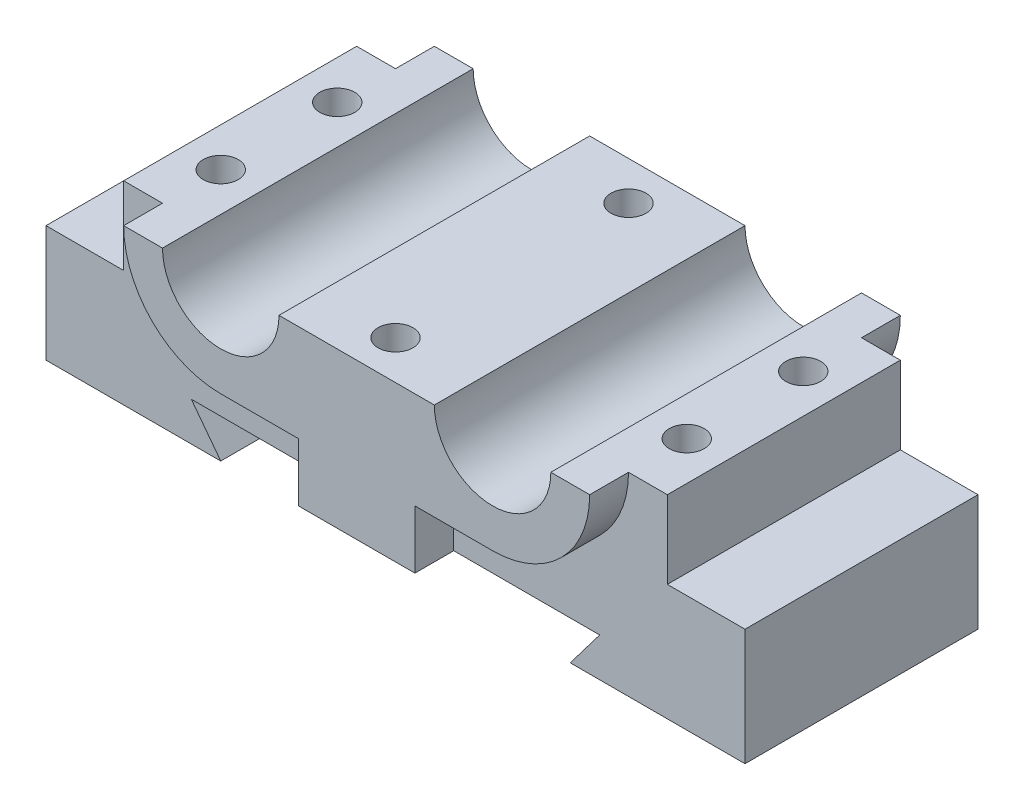
from build123d import *

# Parameters (mm, degrees)
SKETCH1_W                = 90
SKETCH1_H                = 30
BOSS_EXTRUDE1_DEPTH      = 7.5
SKETCH2_W                = 70
SKETCH2_H                = 30
BOSS_EXTRUDE2_DEPTH      = 10
CUT_EXTRUDE1_DEPTH       = 31
BOSS_EXTRUDE3_DEPTH      = 5
BOSS_EXTRUDE3_DEPTH_BACK = 35
CUT_EXTRUDE2_DEPTH       = 30
SKETCH7_R                = 2.25
CUT_EXTRUDE3_DEPTH       = 15


with BuildPart() as part:
    # Sketch1 → Boss-Extrude1 (new body, symmetric)
    with BuildSketch(Plane(origin=(0, 0, 0), x_dir=(1, 0, 0), z_dir=(0, 1, 0))):
        Rectangle(SKETCH1_W, SKETCH1_H)
    extrude(amount=BOSS_EXTRUDE1_DEPTH, both=True)

    # Sketch2 → Boss-Extrude2 (add)
    with BuildSketch(Plane(origin=(0, 7.5, 0), x_dir=(1, 0, 0), z_dir=(0, 1, 0))):
        Rectangle(SKETCH2_W, SKETCH2_H)
    extrude(amount=BOSS_EXTRUDE2_DEPTH)

    # Sketch3 → Cut-Extrude1 (cut, through all)
    with BuildSketch(Plane.XY.offset(15)):
        Polygon((-26.286782916, -2.5), (26.286782916, -2.5), (22.5, -7.5), (-22.5, -7.5), align=None)
    extrude(amount=-CUT_EXTRUDE1_DEPTH, mode=Mode.SUBTRACT)

    # Sketch4 → Boss-Extrude3 (add, two sides)
    with BuildSketch(Plane.XY.offset(15)) as boss_extrude3_sk:
        with BuildLine():
            Line((-7.5, 5), (-7.5, -2.5))
            Line((-7.5, -2.5), (7.5, -2.5))
            Line((7.5, -2.5), (7.5, 5))
            Line((7.5, 5), (17.5, 5))
            ThreePointArc((17.5, 5), (26.338834765, 8.661165235), (30, 17.5))
            Line((30, 17.5), (25, 17.5))
            ThreePointArc((25, 17.5), (17.5, 10), (10, 17.5))
            Line((10, 17.5), (-10, 17.5))
            ThreePointArc((-10, 17.5), (-17.5, 10), (-25, 17.5))
            Line((-25, 17.5), (-30, 17.5))
            ThreePointArc((-30, 17.5), (-26.338834765, 8.661165235), (-17.5, 5))
            Line((-17.5, 5), (-7.5, 5))
        make_face()
    extrude(amount=BOSS_EXTRUDE3_DEPTH)
    extrude(boss_extrude3_sk.sketch, amount=-BOSS_EXTRUDE3_DEPTH_BACK)

    # Sketch6 → Cut-Extrude2 (cut)
    with BuildSketch(Plane.XY.offset(15)):
        with BuildLine():
            Line((-25, 17.5), (-10, 17.5))
            ThreePointArc((-10, 17.5), (-17.5, 10), (-25, 17.5))
        make_face()
        with BuildLine():
            Line((10, 17.5), (25, 17.5))
            ThreePointArc((25, 17.5), (17.5, 10), (10, 17.5))
        make_face()
    extrude(amount=-CUT_EXTRUDE2_DEPTH, mode=Mode.SUBTRACT)

    # Sketch7 → Cut-Extrude3 (cut)
    with BuildSketch(Plane(origin=(0, 17.5, 0), x_dir=(1, 0, 0), z_dir=(0, 1, 0))):
        with Locations((0, 15)):
            Circle(SKETCH7_R)
        with Locations((0, -15)):
            Circle(SKETCH7_R)
        with Locations((-30, 7.5)):
            Circle(SKETCH7_R)
        with Locations((-30, -7.5)):
            Circle(SKETCH7_R)
        with Locations((30, -7.5)):
            Circle(SKETCH7_R)
        with Locations((30, 7.5)):
            Circle(SKETCH7_R)
    extrude(amount=-CUT_EXTRUDE3_DEPTH, mode=Mode.SUBTRACT)


solid = part.part
